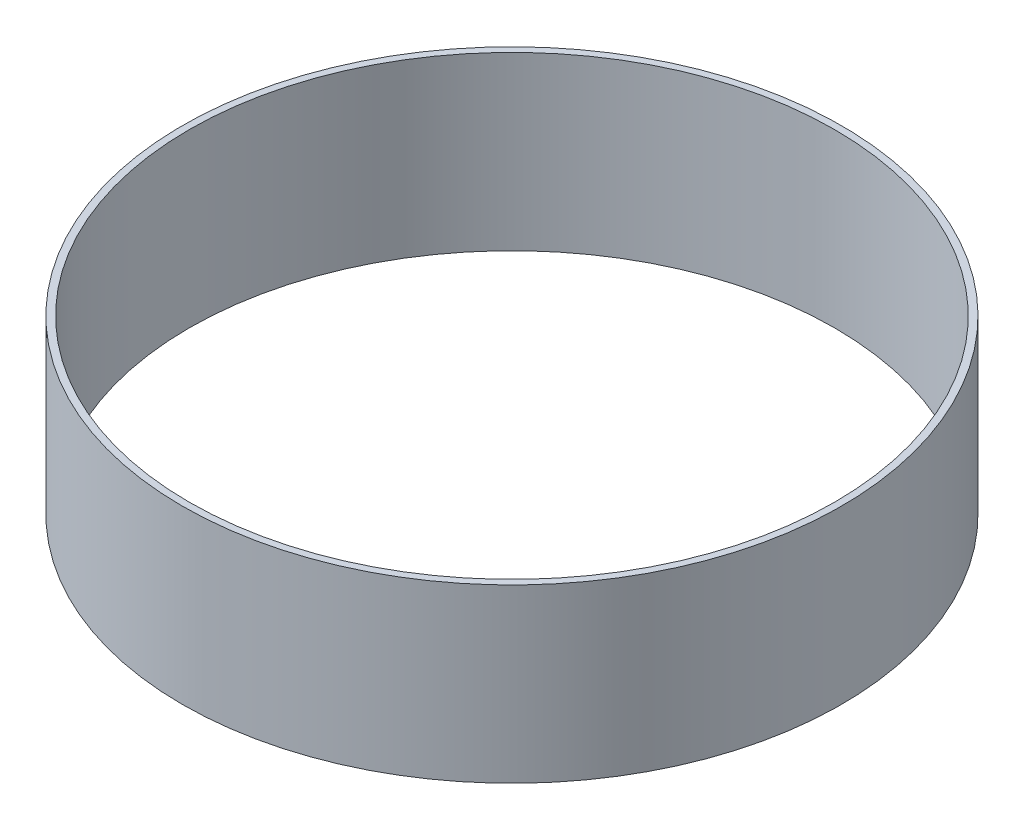
from build123d import *

# Parameters (mm, degrees)
SKETCH1_R           = 97.4725
SKETCH1_R_2         = 95.4405
BOSS_EXTRUDE1_DEPTH = 50.8


with BuildPart() as part:
    # Sketch1 → Boss-Extrude1 (new body)
    with BuildSketch(Plane(origin=(0, 0, 0), x_dir=(1, 0, 0), z_dir=(0, 1, 0))):
        Circle(SKETCH1_R)
        Circle(SKETCH1_R_2, mode=Mode.SUBTRACT)
    extrude(amount=BOSS_EXTRUDE1_DEPTH)


solid = part.part
